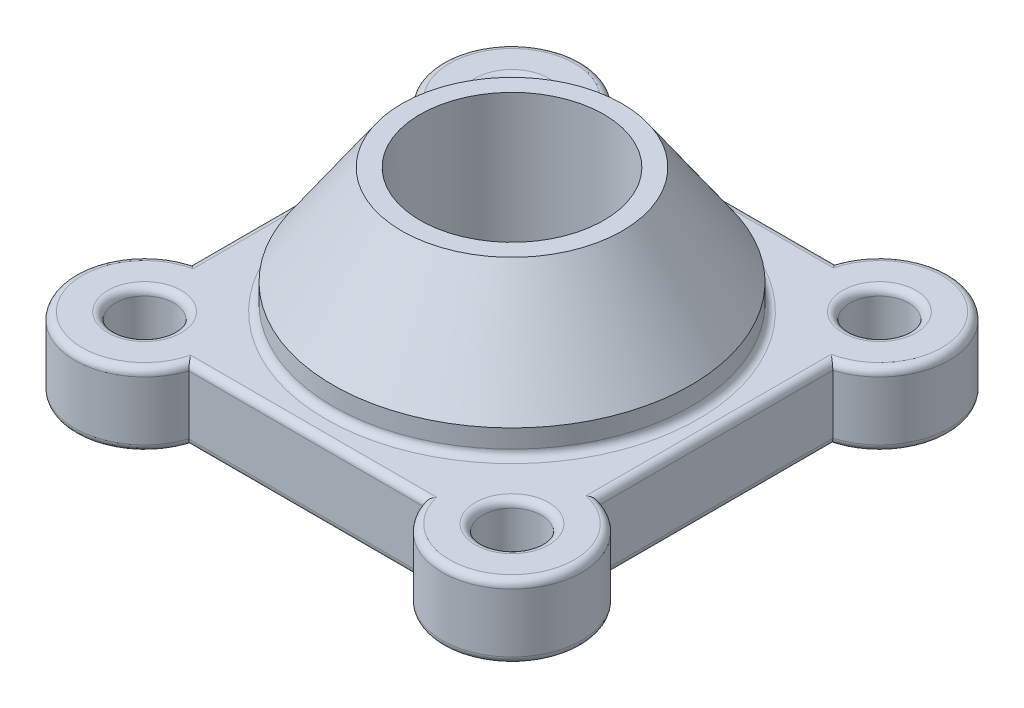
from build123d import *

# Parameters (mm, degrees)
SKETCH1_W           = 55.5
SKETCH1_H           = 56
BOSS_EXTRUDE1_DEPTH = 10
BOSS_EXTRUDE2_DEPTH = 10
SKETCH2_3_R         = 4
CUT_EXTRUDE1_DEPTH  = 10
FILLET1_R           = 1
FILLET2_R           = 1
SKETCH4_R           = 12.5
CUT_EXTRUDE2_DEPTH  = 27


with BuildPart() as part:
    # Sketch1 → Boss-Extrude1 (new body)
    with BuildSketch(Plane(origin=(0, 0, 0), x_dir=(1, 0, 0), z_dir=(0, 1, 0))):
        with Locations((27.75, 28)):
            Rectangle(SKETCH1_W, SKETCH1_H)
    extrude(amount=BOSS_EXTRUDE1_DEPTH)

    # Sketch2 → Boss-Extrude2 (add)
    with BuildSketch(Plane(origin=(0, 10, 0), x_dir=(1, 0, 0), z_dir=(0, 1, 0))):
        with BuildLine():
            ThreePointArc((11.763878189, 0), (12.127682091, 1.480434732), (12.25, 3))
            ThreePointArc((12.25, 3), (8.412375826, 10.628073151), (0, 12.09326674))
            Line((0, 12.09326674), (0, 5.90473751))
            ThreePointArc((0, 5.90473751), (4.33113883, 6.674234614), (6.75, 3))
            ThreePointArc((6.75, 3), (6.395751311, 1.354248689), (5.395751311, 0))
            Line((5.395751311, 0), (11.763878189, 0))
        make_face()
        with BuildLine():
            Line((0, 5.90473751), (0, 12.09326674))
            ThreePointArc((0, 12.09326674), (-4.059612148, -3.624136351), (11.763878189, 0))
            Line((11.763878189, 0), (5.395751311, 0))
            ThreePointArc((5.395751311, 0), (2.75, -1), (0.104248689, 0))
            Line((0.104248689, 0), (0, 0))
            Line((0, 0), (0, 0.09526249))
            ThreePointArc((0, 0.09526249), (-1.25, 3), (0, 5.90473751))
        make_face()
        with BuildLine():
            Line((0, 50.09526249), (0, 43.90673326))
            ThreePointArc((0, 43.90673326), (8.412375826, 45.371926849), (12.25, 53))
            ThreePointArc((12.25, 53), (12.127682091, 54.519565268), (11.763878189, 56))
            Line((11.763878189, 56), (5.395751311, 56))
            ThreePointArc((5.395751311, 56), (6.395751311, 54.645751311), (6.75, 53))
            ThreePointArc((6.75, 53), (4.33113883, 49.325765386), (0, 50.09526249))
        make_face()
        with BuildLine():
            ThreePointArc((11.763878189, 56), (-4.059612148, 59.624136351), (0, 43.90673326))
            Line((0, 43.90673326), (0, 50.09526249))
            ThreePointArc((0, 50.09526249), (-1.25, 53), (0, 55.90473751))
            Line((0, 55.90473751), (0, 56))
            Line((0, 56), (0.104248689, 56))
            ThreePointArc((0.104248689, 56), (2.75, 57), (5.395751311, 56))
            Line((5.395751311, 56), (11.763878189, 56))
        make_face()
        with BuildLine():
            Line((50.104248689, 56), (43.736121811, 56))
            ThreePointArc((43.736121811, 56), (45.940387852, 46.375863649), (55.5, 43.90673326))
            Line((55.5, 43.90673326), (55.5, 50.09526249))
            ThreePointArc((55.5, 50.09526249), (49.797171151, 50.30170391), (50.104248689, 56))
        make_face()
        with BuildLine():
            ThreePointArc((62.25, 53), (54.269565268, 62.377682091), (43.736121811, 56))
            Line((43.736121811, 56), (50.104248689, 56))
            ThreePointArc((50.104248689, 56), (52.75, 57), (55.395751311, 56))
            Line((55.395751311, 56), (55.5, 56))
            Line((55.5, 56), (55.5, 55.90473751))
            ThreePointArc((55.5, 55.90473751), (56.424234614, 54.58113883), (56.75, 53))
            ThreePointArc((56.75, 53), (56.424234614, 51.41886117), (55.5, 50.09526249))
            Line((55.5, 50.09526249), (55.5, 43.90673326))
            ThreePointArc((55.5, 43.90673326), (60.378073151, 47.337624174), (62.25, 53))
        make_face()
        with BuildLine():
            Line((50.104248689, 0), (43.736121811, 0))
            ThreePointArc((43.736121811, 0), (54.269565268, -6.377682091), (62.25, 3))
            ThreePointArc((62.25, 3), (60.378073151, 8.662375826), (55.5, 12.09326674))
            Line((55.5, 12.09326674), (55.5, 5.90473751))
            ThreePointArc((55.5, 5.90473751), (56.424234614, 4.58113883), (56.75, 3))
            ThreePointArc((56.75, 3), (56.424234614, 1.41886117), (55.5, 0.09526249))
            Line((55.5, 0.09526249), (55.5, 0))
            Line((55.5, 0), (55.395751311, 0))
            ThreePointArc((55.395751311, 0), (52.75, -1), (50.104248689, 0))
        make_face()
        with BuildLine():
            ThreePointArc((55.5, 12.09326674), (45.940387852, 9.624136351), (43.736121811, 0))
            Line((43.736121811, 0), (50.104248689, 0))
            ThreePointArc((50.104248689, 0), (49.797171151, 5.69829609), (55.5, 5.90473751))
            Line((55.5, 5.90473751), (55.5, 12.09326674))
        make_face()
    extrude(amount=-BOSS_EXTRUDE2_DEPTH)

    # Sketch2_3 → Cut-Extrude1 (cut)
    with BuildSketch(Plane(origin=(0, 10, 0), x_dir=(1, 0, 0), z_dir=(0, 1, 0))):
        with Locations((2.75, 3)):
            Circle(SKETCH2_3_R)
        with Locations((52.75, 3)):
            Circle(SKETCH2_3_R)
        with Locations((52.75, 53)):
            Circle(SKETCH2_3_R)
        with Locations((2.75, 53)):
            Circle(SKETCH2_3_R)
    extrude(amount=-CUT_EXTRUDE1_DEPTH, mode=Mode.SUBTRACT)

    # Fillet1
    fillet1_edges = [part.edges().sort_by_distance(p)[0] for p in [
        (27.75, 10, 0),
        (0, 10, -28),
        (2.75, 10, 1),
        (-4.059612148, 10, 3.624136351),
        (27.75, 10, -56),
        (4.33113883, 10, -49.325765386),
        (-4.059612148, 10, -59.624136351),
        (49.797171151, 10, -50.30170391),
        (59.559612148, 10, -59.624136351),
        (55.5, 10, -28),
        (52.75, 10, 1),
        (59.559612148, 10, 3.624136351),
    ]]
    fillet(fillet1_edges, radius=FILLET1_R)

    # Sketch3 → Revolve1 (revolve)
    with BuildSketch(Plane.XY.offset(-28)):
        Polygon((40.25, 10), (52.1, 10), (52.1, 13.5), (42.752156821, 27), (40.25, 27), align=None)
    revolve(axis=Axis((27.75, -3.834604124, -28), (0, 1, 0)))

    # Fillet2
    fillet2_edges = [part.edges().sort_by_distance(p)[0] for p in [
        (27.75, 0, 0),
        (0, 0, -28),
        (3.4, 10, -28),
        (-4.059612148, 0, 3.624136351),
        (2.75, 0, 1),
        (27.75, 0, -56),
        (-4.059612148, 0, -59.624136351),
        (4.33113883, 0, -49.325765386),
        (59.559612148, 0, -59.624136351),
        (49.797171151, 0, -50.30170391),
        (55.5, 0, -28),
        (59.559612148, 0, 3.624136351),
        (52.75, 0, 1),
    ]]
    fillet(fillet2_edges, radius=FILLET2_R)

    # Sketch4 → Cut-Extrude2 (cut)
    with BuildSketch(Plane(origin=(0, 27, 0), x_dir=(1, 0, 0), z_dir=(0, 1, 0))):
        with Locations((27.75, 28)):
            Circle(SKETCH4_R)
    extrude(amount=-CUT_EXTRUDE2_DEPTH, mode=Mode.SUBTRACT)


solid = part.part
